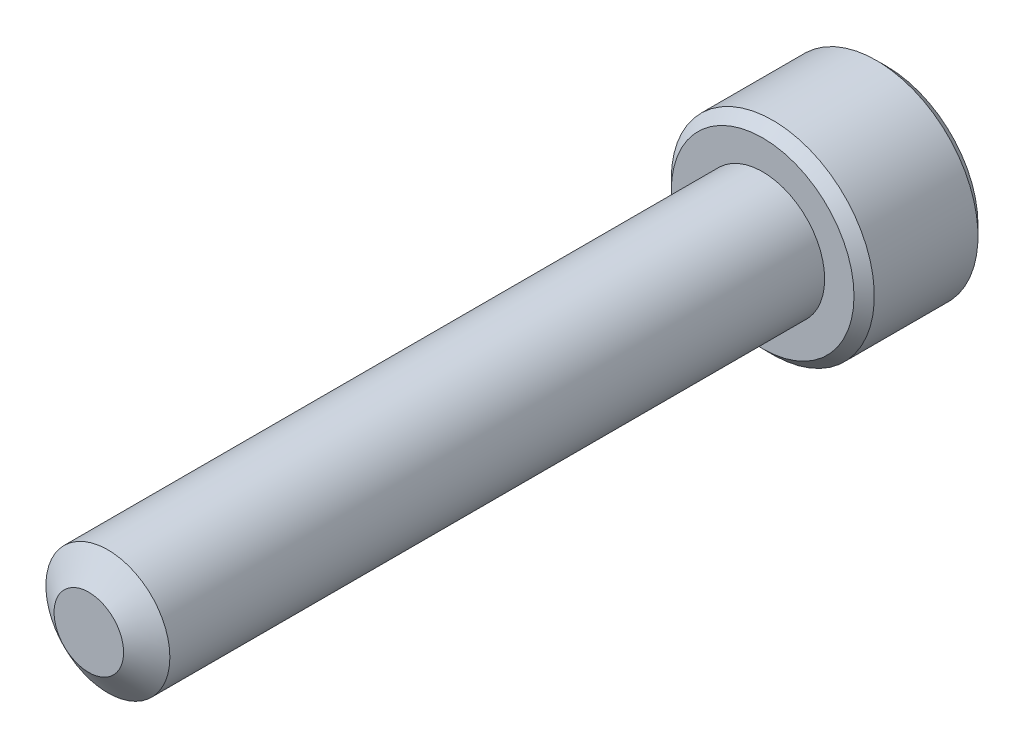
from build123d import *

# Parameters (mm, degrees)
SKETCH1_R          = 1.7526
EXTRUDE1_DEPTH     = 19.05
SKETCH6_R          = 2.8702
EXTRUDE2_DEPTH     = 3.5052
CUT_EXTRUDE1_DEPTH = 2.08359375
CHAMFER1_SIZE      = 0.28702


with BuildPart() as part:
    # Sketch1 → Extrude1 (new body)
    with BuildSketch(Plane.XY):
        Circle(SKETCH1_R)
    extrude(amount=-EXTRUDE1_DEPTH)

    # Sketch4 → Cut-Revolve1 (revolve, cut)
    with BuildSketch(Plane(origin=(0, 0, 0), x_dir=(0, 0, -1), z_dir=(1, 0, 0))):
        Polygon((0.538848736, 1.7526), (0, 0.983044252), (0, 1.7526), align=None)
    revolve(axis=Axis((0, 0, 0), (0, 0, -1)), mode=Mode.SUBTRACT)

    # Sketch6 → Extrude2 (add)
    with BuildSketch(Plane(origin=(0, 0, -19.05), x_dir=(-1, 0, 0), z_dir=(0, 0, -1))):
        Circle(SKETCH6_R)
    extrude(amount=EXTRUDE2_DEPTH)

    # Sketch7 → Cut-Extrude1 (cut)
    with BuildSketch(Plane(origin=(0, 0, -22.5552), x_dir=(-1, 0, 0), z_dir=(0, 0, -1))):
        Polygon((0, 1.603951217), (-1.3890625, 0.801975608), (-1.3890625, -0.801975608), (0, -1.603951217), (1.3890625, -0.801975608), (1.3890625, 0.801975608), align=None)
    extrude(amount=-CUT_EXTRUDE1_DEPTH, mode=Mode.SUBTRACT)

    # Cut-Extrude2 cone 1 section (through the dimple's axis) → Cut-Extrude2 (revolve, cut)
    with BuildSketch(Plane(origin=(0, 0, -22.5552), x_dir=(0, 1, 0), z_dir=(1, 0, 0))):
        Polygon((0, 0), (1.603951217, 0), (0, 1.603951217), align=None)
    revolve(axis=Axis((0, 0, -22.5552), (0, 0, 1)), mode=Mode.SUBTRACT)

    # Chamfer1
    chamfer1_edges = [part.edges().sort_by_distance(p)[0] for p in [
        (2.8702, 0, -22.5552),
        (2.8702, 0, -19.05),
    ]]
    chamfer(chamfer1_edges, length=CHAMFER1_SIZE)


solid = part.part
